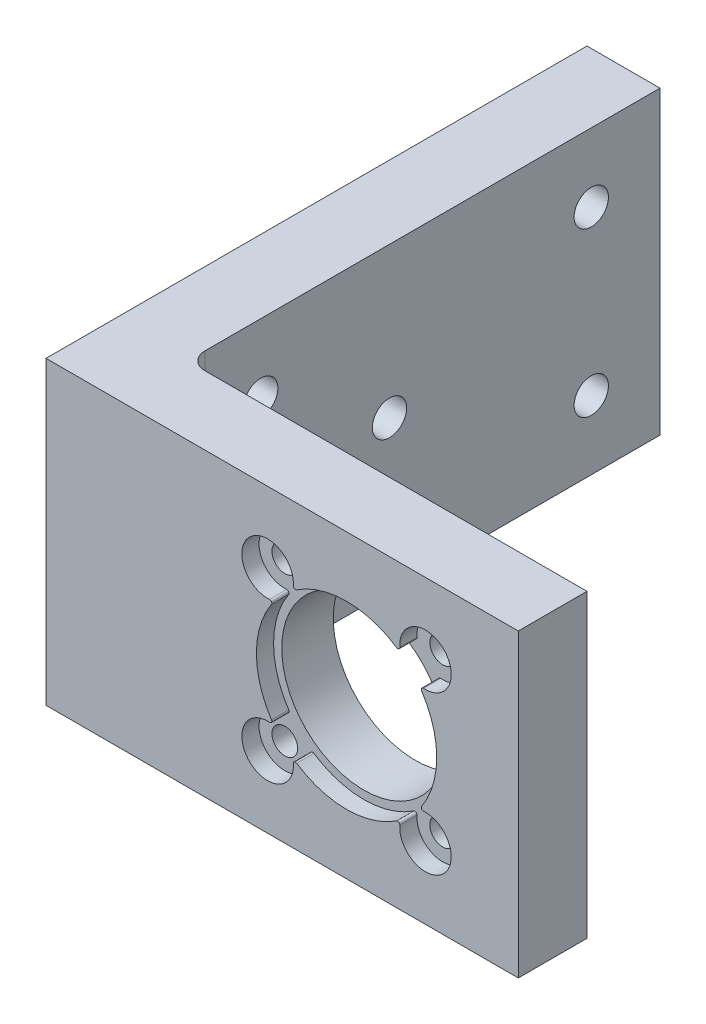
from build123d import *

# Parameters (mm, degrees)
SKETCH1_W           = 55
SKETCH1_H           = 35
SKETCH1_R           = 9.55
SKETCH1_R_2         = 1.5
BOSS_EXTRUDE3_DEPTH = 6
SKETCH4_W           = 55
SKETCH4_H           = 35
BOSS_EXTRUDE5_DEPTH = 2
SKETCH8_W           = 8.5
SKETCH8_H           = 35
BOSS_EXTRUDE6_DEPTH = 55
SKETCH9_R           = 2
CUT_EXTRUDE1_DEPTH  = 8.5
FILLET1_R           = 2


with BuildPart() as part:
    # Sketch1 → Boss-Extrude3 (new body)
    with BuildSketch(Plane.XY):
        with Locations((27.5, 17.5)):
            Rectangle(SKETCH1_W, SKETCH1_H)
        with Locations((35, 17.5)):
            Circle(SKETCH1_R, mode=Mode.SUBTRACT)
        with Locations((44.192388155, 26.692388155)):
            Circle(SKETCH1_R_2, mode=Mode.SUBTRACT)
        with Locations((44.192388155, 8.307611845)):
            Circle(SKETCH1_R_2, mode=Mode.SUBTRACT)
        with Locations((25.807611845, 8.307611845)):
            Circle(SKETCH1_R_2, mode=Mode.SUBTRACT)
        with Locations((25.807611845, 26.692388155)):
            Circle(SKETCH1_R_2, mode=Mode.SUBTRACT)
    extrude(amount=BOSS_EXTRUDE3_DEPTH)

    # Sketch4 → Boss-Extrude5 (add)
    with BuildSketch(Plane.XY.offset(6)):
        with Locations((27.5, 17.5)):
            Rectangle(SKETCH4_W, SKETCH4_H)
        with BuildLine():
            ThreePointArc((28.799419693, 26.47083501), (23.686291501, 28.813708499), (26.02916499, 23.700580307))
            ThreePointArc((26.02916499, 23.700580307), (26.263454109, 23.57743344), (26.255822455, 23.312861521))
            ThreePointArc((26.255822455, 23.312861521), (24.5, 17.5), (26.255822455, 11.687138479))
            ThreePointArc((26.255822455, 11.687138479), (26.263454109, 11.42256656), (26.02916499, 11.299419693))
            ThreePointArc((26.02916499, 11.299419693), (23.686291501, 6.186291501), (28.799419693, 8.52916499))
            ThreePointArc((28.799419693, 8.52916499), (28.92256656, 8.763454109), (29.187138479, 8.755822455))
            ThreePointArc((29.187138479, 8.755822455), (35, 7), (40.812861521, 8.755822455))
            ThreePointArc((40.812861521, 8.755822455), (41.07743344, 8.763454109), (41.200580307, 8.52916499))
            ThreePointArc((41.200580307, 8.52916499), (46.313708499, 6.186291501), (43.97083501, 11.299419693))
            ThreePointArc((43.97083501, 11.299419693), (43.736545891, 11.42256656), (43.744177545, 11.687138479))
            ThreePointArc((43.744177545, 11.687138479), (45.5, 17.5), (43.744177545, 23.312861521))
            ThreePointArc((43.744177545, 23.312861521), (43.736545891, 23.57743344), (43.97083501, 23.700580307))
            ThreePointArc((43.97083501, 23.700580307), (46.313708499, 28.813708499), (41.200580307, 26.47083501))
            ThreePointArc((41.200580307, 26.47083501), (41.07743344, 26.236545891), (40.812861521, 26.244177545))
            ThreePointArc((40.812861521, 26.244177545), (35, 28), (29.187138479, 26.244177545))
            ThreePointArc((29.187138479, 26.244177545), (28.92256656, 26.236545891), (28.799419693, 26.47083501))
        make_face(mode=Mode.SUBTRACT)
    extrude(amount=BOSS_EXTRUDE5_DEPTH)

    # Sketch8 → Boss-Extrude6 (add)
    with BuildSketch(Plane(origin=(0, 0, 0), x_dir=(-1, 0, 0), z_dir=(0, 0, -1))):
        with Locations((-4.25, 17.5)):
            Rectangle(SKETCH8_W, SKETCH8_H)
    extrude(amount=BOSS_EXTRUDE6_DEPTH)

    # Sketch9 → Cut-Extrude1 (cut)
    with BuildSketch(Plane.ZY):
        with Locations((-47, 27)):
            Circle(SKETCH9_R)
        with Locations((-47, 8)):
            Circle(SKETCH9_R)
        with Locations((-8.5, 27)):
            Circle(SKETCH9_R)
        with Locations((-8.5, 8)):
            Circle(SKETCH9_R)
        with Locations((-23.5, 17.5)):
            Circle(SKETCH9_R)
    extrude(amount=-CUT_EXTRUDE1_DEPTH, mode=Mode.SUBTRACT)

    # Fillet1
    fillet1_edges = [part.edges().sort_by_distance(p)[0] for p in [
        (8.5, 17.5, 0),
    ]]
    fillet(fillet1_edges, radius=FILLET1_R)


solid = part.part
